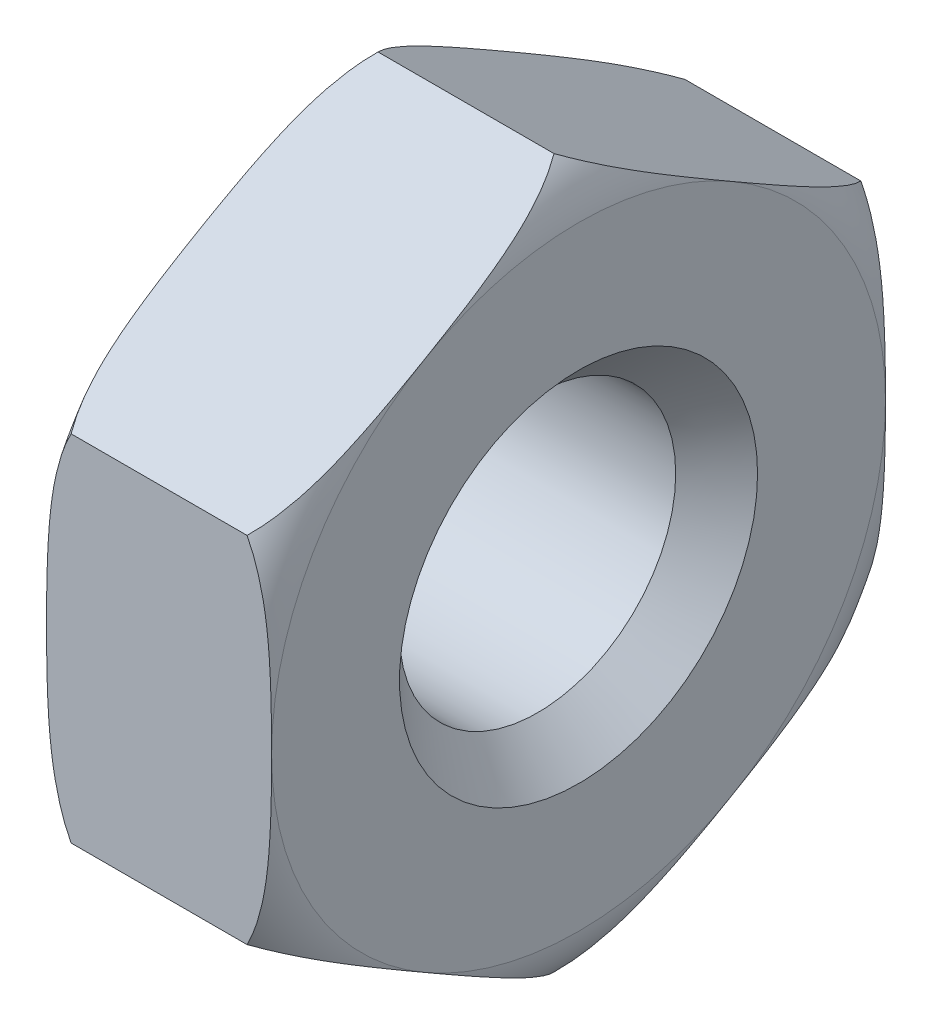
from build123d import *

# Parameters (mm, degrees)
EXTRUSION1_DEPTH        = 7
ESQUISSE3_R             = 3.375
ENL_V_MAT_EXTRU_1_DEPTH = 8
CHANFREIN1_SIZE         = 1


with BuildPart() as part:
    # Esquisse1 → Extrusion1 (new body)
    with BuildSketch(Plane(origin=(0, 0, 0), x_dir=(0, 0, -1), z_dir=(1, 0, 0))):
        Polygon((0, 8.660254038), (-7.5, 4.330127019), (-7.5, -4.330127019), (0, -8.660254038), (7.5, -4.330127019), (7.5, 4.330127019), align=None)
    extrude(amount=EXTRUSION1_DEPTH)

    # Esquisse2 → Enlèvement de matière-Révolution1 (revolve, cut)
    with BuildSketch(Plane.XY, mode=Mode.PRIVATE) as enl_vement_de_mati_re_r_volution1_sk:
        with BuildLine():
            Line((1.5, 6.75), (1.5, 8.660254038))
            Line((1.5, 8.660254038), (0, 8.660254038))
            Line((0, 8.660254038), (0, 5.25))
            ThreePointArc((0, 5.25), (1.060660172, 5.689339828), (1.5, 6.75))
        make_face()
    revolve(enl_vement_de_mati_re_r_volution1_sk.sketch.rotate(Axis((-3.040359493, 0, 0), (1, 0, 0)), 90), axis=Axis((-3.040359493, 0, 0), (1, 0, 0)), mode=Mode.SUBTRACT)  # turned: the seam where the file's is

    # Esquisse3 → Enlèv. mat.-Extru.1 (cut, through all)
    with BuildSketch(Plane.ZY):
        Circle(ESQUISSE3_R)
    extrude(amount=-ENL_V_MAT_EXTRU_1_DEPTH, mode=Mode.SUBTRACT)

    # Chanfrein1
    chanfrein1_edges = [part.edges().sort_by_distance(p)[0] for p in [
        (7, 0, -3.375),
        (0, 0, -3.375),
    ]]
    chamfer(chanfrein1_edges, length=CHANFREIN1_SIZE)

    # Esquisse4 → Enlèvement de matière-Révolution2 (revolve, cut)
    with BuildSketch(Plane.XY, mode=Mode.PRIVATE) as enl_vement_de_mati_re_r_volution2_sk:
        with BuildLine():
            Line((1.5, 8.660254038), (2.1, 8.660254038))
            ThreePointArc((2.1, 8.660254038), (1.70260937, 8.130490453), (1.5, 7.5))
            Line((1.5, 7.5), (1.5, 8.660254038))
        make_face()
        with BuildLine():
            Line((7, 8.660254038), (7, 7.5))
            ThreePointArc((7, 7.5), (6.79739063, 8.130490453), (6.4, 8.660254038))
            Line((6.4, 8.660254038), (7, 8.660254038))
        make_face()
    revolve(enl_vement_de_mati_re_r_volution2_sk.sketch.rotate(Axis((0, 0, 0), (1, 0, 0)), 270), axis=Axis((0, 0, 0), (1, 0, 0)), mode=Mode.SUBTRACT)  # turned: the seam where the file's is


solid = part.part
